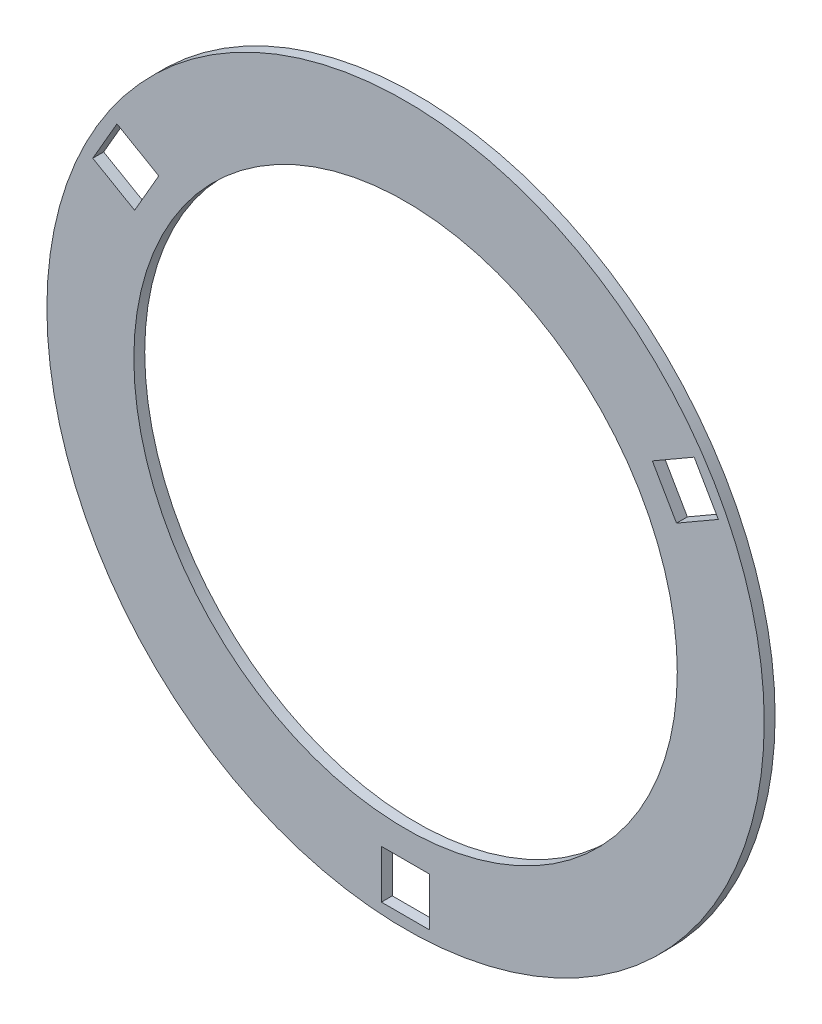
from build123d import *

# Parameters (mm, degrees)
SKETCH2_R           = 330
SKETCH2_R_2         = 250
SKETCH2_W           = 44.45
SKETCH2_H           = 44.45
BOSS_EXTRUDE1_DEPTH = 10


with BuildPart() as part:
    # Sketch2 → Boss-Extrude1 (new body)
    with BuildSketch(Plane.XY):
        with Locations((-7.257473883, -45.051995239)):
            Circle(SKETCH2_R)
        with Locations((-7.257473883, -45.051995239)):
            Circle(SKETCH2_R_2, mode=Mode.SUBTRACT)
        Polygon((-272.796789122, 133.92041936), (-295.021789122, 95.425590162), (-256.526959924, 73.200590162), (-234.301959924, 111.69541936), align=None, mode=Mode.SUBTRACT)
        Polygon((258.281841356, 133.92041936), (219.787012158, 111.69541936), (242.012012158, 73.200590162), (280.506841356, 95.425590162), align=None, mode=Mode.SUBTRACT)
        with Locations((-7.257473883, -342.276995239)):
            Rectangle(SKETCH2_W, SKETCH2_H, mode=Mode.SUBTRACT)
    extrude(amount=BOSS_EXTRUDE1_DEPTH)


solid = part.part
